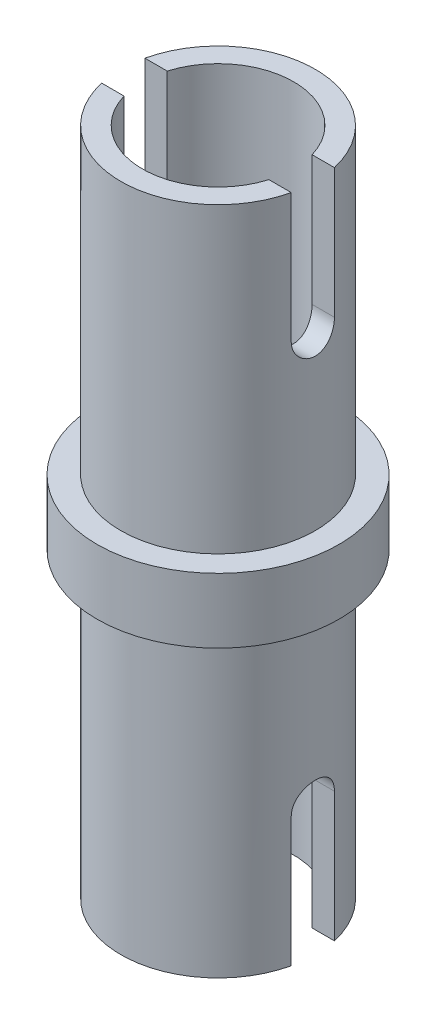
from build123d import *

# Parameters (mm, degrees)
SKETCH1_R           = 2.8
BOSS_EXTRUDE1_DEPTH = 1.5
SKETCH2_R           = 2.25
BOSS_EXTRUDE2_DEPTH = 7
SKETCH3_R           = 2.25
BOSS_EXTRUDE3_DEPTH = 7
CUT_EXTRUDE1_DEPTH  = 103.8
SKETCH5_R           = 1.75
CUT_EXTRUDE2_DEPTH  = 108.0000001


with BuildPart() as part:
    # Sketch1 → Boss-Extrude1 (new body)
    with BuildSketch(Plane(origin=(0, 0, 0), x_dir=(1, 0, 0), z_dir=(0, 1, 0))):
        Circle(SKETCH1_R)
    extrude(amount=BOSS_EXTRUDE1_DEPTH)

    # Sketch2 → Boss-Extrude2 (add)
    with BuildSketch(Plane(origin=(0, 1.5, 0), x_dir=(1, 0, 0), z_dir=(0, 1, 0))):
        Circle(SKETCH2_R)
    extrude(amount=BOSS_EXTRUDE2_DEPTH)

    # Sketch3 → Boss-Extrude3 (add)
    with BuildSketch(Plane.XZ):
        Circle(SKETCH3_R)
    extrude(amount=BOSS_EXTRUDE3_DEPTH)

    # Sketch4 → Cut-Extrude1 (cut, through all)
    with BuildSketch(Plane(origin=(100, 0, 0), x_dir=(0, 0, -1), z_dir=(1, 0, 0))):
        with BuildLine():
            Line((-0.5, 5.5), (-0.5, 8.5))
            ThreePointArc((-0.5, 8.5), (0, 9), (0.5, 8.5))
            Line((0.5, 8.5), (0.5, 5.5))
            ThreePointArc((0.5, 5.5), (0, 5), (-0.5, 5.5))
        make_face()
        with BuildLine():
            Line((0.5, -4), (0.5, -7))
            ThreePointArc((0.5, -7), (0, -7.5), (-0.5, -7))
            Line((-0.5, -7), (-0.5, -4))
            ThreePointArc((-0.5, -4), (0, -3.5), (0.5, -4))
        make_face()
    extrude(amount=-CUT_EXTRUDE1_DEPTH, mode=Mode.SUBTRACT)

    # Sketch5 → Cut-Extrude2 (cut, through all)
    with BuildSketch(Plane(origin=(0, 100, 0), x_dir=(1, 0, 0), z_dir=(0, 1, 0))):
        Circle(SKETCH5_R)
    extrude(amount=-CUT_EXTRUDE2_DEPTH, mode=Mode.SUBTRACT)


solid = part.part
